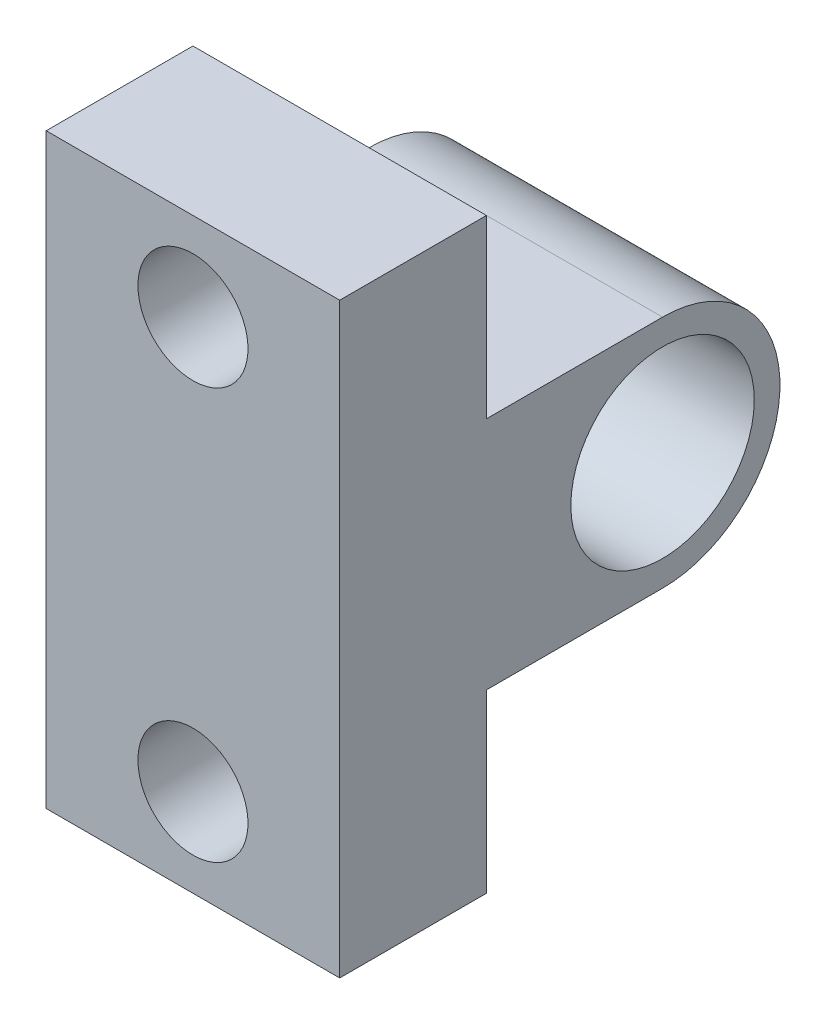
from build123d import *

# Parameters (mm, degrees)
SKETCH1_R           = 3.96875
BOSS_EXTRUDE1_DEPTH = 12.7
SKETCH2_R           = 2.38125
CUT_EXTRUDE1_DEPTH  = 7.35


with BuildPart() as part:
    # Sketch1 → Boss-Extrude1 (new body)
    with BuildSketch(Plane(origin=(0, 0, 0), x_dir=(0, 0, -1), z_dir=(1, 0, 0))):
        with BuildLine():
            Line((-26.587134527, 4.994963407), (-26.587134527, -2.625036593))
            Line((-26.587134527, -2.625036593), (-32.937134527, -2.625036593))
            Line((-32.937134527, -2.625036593), (-32.937134527, 22.774963407))
            Line((-32.937134527, 22.774963407), (-26.587134527, 22.774963407))
            Line((-26.587134527, 22.774963407), (-26.587134527, 15.154963407))
            Line((-26.587134527, 15.154963407), (-18.967134527, 15.154963407))
            ThreePointArc((-18.967134527, 15.154963407), (-13.887134527, 10.074963407), (-18.967134527, 4.994963407))
            Line((-18.967134527, 4.994963407), (-26.587134527, 4.994963407))
        make_face()
        with Locations((-18.967134527, 10.074963407)):
            Circle(SKETCH1_R, mode=Mode.SUBTRACT)
    extrude(amount=BOSS_EXTRUDE1_DEPTH)

    # Sketch2 → Cut-Extrude1 (cut, through all)
    with BuildSketch(Plane(origin=(0, 0, 26.587134527), x_dir=(-1, 0, 0), z_dir=(0, 0, -1))):
        with Locations((-6.35, 18.964963407)):
            Circle(SKETCH2_R)
        with Locations((-6.35, 1.184963407)):
            Circle(SKETCH2_R)
    extrude(amount=-CUT_EXTRUDE1_DEPTH, mode=Mode.SUBTRACT)


solid = part.part
